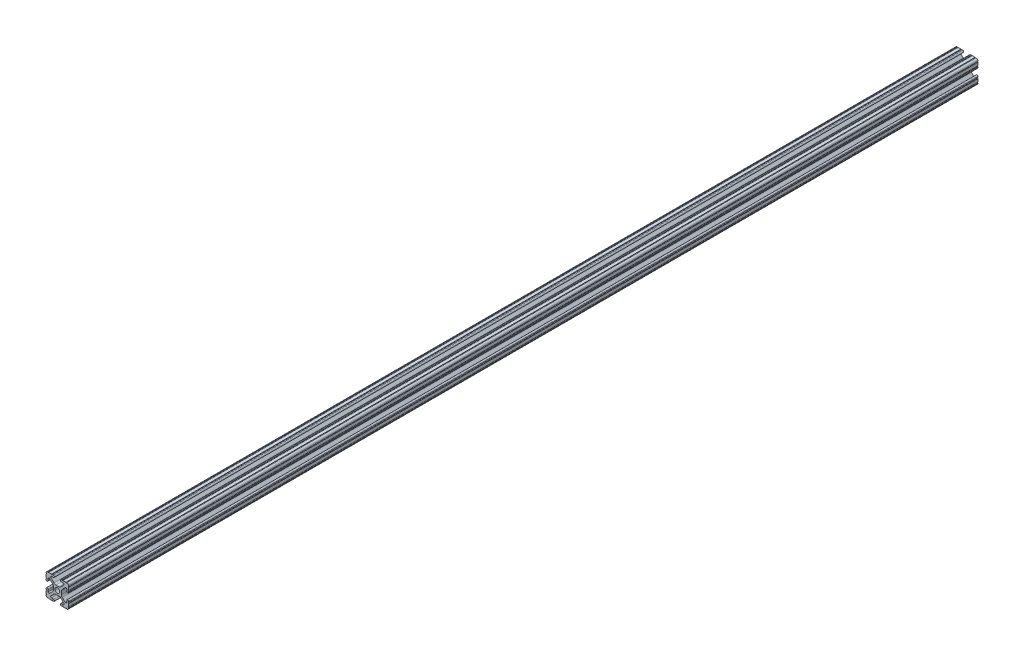
from build123d import *

# Parameters (mm, degrees)
SKETCH1_R           = 2.6035
BOSS_EXTRUDE1_DEPTH = 1016


with BuildPart() as part:
    # Sketch1 → Boss-Extrude1 (new body)
    with BuildSketch(Plane(origin=(0, 0, -450.85), x_dir=(-1, 0, 0), z_dir=(0, 0, -1))):
        with BuildLine():
            Line((12.7, -9.5504), (12.7, -6.3330836))
            ThreePointArc((12.7, -6.3330836), (12.192, -5.8250836), (12.7, -5.3170836))
            Line((12.7, -5.3170836), (12.7, -4.3434))
            ThreePointArc((12.7, -4.3434), (11.5951, -3.2385), (10.4902, -4.3434))
            Line((10.4902, -4.3434), (10.4902, -6.474794456))
            ThreePointArc((10.4902, -6.474794456), (9.863006367, -7.413456061), (8.75577951, -7.193214945))
            Line((8.75577951, -7.193214945), (5.42573597, -3.863171405))
            ThreePointArc((5.42573597, -3.863171405), (4.737482484, -2.833127272), (4.4958, -1.618107374))
            Line((4.4958, -1.618107374), (4.4958, 1.618107374))
            ThreePointArc((4.4958, 1.618107374), (4.737482484, 2.833127272), (5.42573597, 3.863171405))
            Line((5.42573597, 3.863171405), (8.75577951, 7.193214945))
            ThreePointArc((8.75577951, 7.193214945), (9.863006367, 7.413456061), (10.4902, 6.474794456))
            Line((10.4902, 6.474794456), (10.4902, 4.343399971))
            ThreePointArc((10.4902, 4.343399971), (11.5951, 3.238499971), (12.7, 4.343399971))
            Line((12.7, 4.343399971), (12.7, 5.3170836))
            ThreePointArc((12.7, 5.3170836), (12.192, 5.8250836), (12.7, 6.3330836))
            Line((12.7, 6.3330836), (12.7, 9.5504))
            ThreePointArc((12.7, 9.5504), (12.192000006, 10.058323491), (12.699846982, 10.566399977))
            ThreePointArc((12.699846982, 10.566399977), (12.082522516, 12.082522516), (10.566399977, 12.699846982))
            ThreePointArc((10.566399977, 12.699846982), (10.058323491, 12.192000006), (9.5504, 12.7))
            Line((9.5504, 12.7), (6.3330836, 12.7))
            ThreePointArc((6.3330836, 12.7), (5.8250836, 12.192), (5.3170836, 12.7))
            Line((5.3170836, 12.7), (4.3434, 12.7))
            ThreePointArc((4.3434, 12.7), (3.2385, 11.5951), (4.3434, 10.4902))
            Line((4.3434, 10.4902), (6.474794456, 10.4902))
            ThreePointArc((6.474794456, 10.4902), (7.413456061, 9.863006367), (7.193214945, 8.75577951))
            Line((7.193214945, 8.75577951), (3.863171405, 5.42573597))
            ThreePointArc((3.863171405, 5.42573597), (2.833127272, 4.737482484), (1.618107374, 4.4958))
            Line((1.618107374, 4.4958), (-1.618107374, 4.4958))
            ThreePointArc((-1.618107374, 4.4958), (-2.833127272, 4.737482484), (-3.863171405, 5.42573597))
            Line((-3.863171405, 5.42573597), (-7.193214945, 8.75577951))
            ThreePointArc((-7.193214945, 8.75577951), (-7.413456061, 9.863006367), (-6.474794456, 10.4902))
            Line((-6.474794456, 10.4902), (-4.343399971, 10.4902))
            ThreePointArc((-4.343399971, 10.4902), (-3.238499971, 11.5951), (-4.343399971, 12.7))
            Line((-4.343399971, 12.7), (-5.3170836, 12.7))
            ThreePointArc((-5.3170836, 12.7), (-5.8250836, 12.192), (-6.3330836, 12.7))
            Line((-6.3330836, 12.7), (-9.5504, 12.7))
            ThreePointArc((-9.5504, 12.7), (-10.058323491, 12.192000006), (-10.566399977, 12.699846982))
            ThreePointArc((-10.566399977, 12.699846982), (-12.082522516, 12.082522516), (-12.699846982, 10.566399977))
            ThreePointArc((-12.699846982, 10.566399977), (-12.192000006, 10.058323491), (-12.7, 9.5504))
            Line((-12.7, 9.5504), (-12.7, 6.3330836))
            ThreePointArc((-12.7, 6.3330836), (-12.192, 5.8250836), (-12.7, 5.3170836))
            Line((-12.7, 5.3170836), (-12.7, 4.3434))
            ThreePointArc((-12.7, 4.3434), (-11.5951, 3.2385), (-10.4902, 4.3434))
            Line((-10.4902, 4.3434), (-10.4902, 6.474794456))
            ThreePointArc((-10.4902, 6.474794456), (-9.863006367, 7.413456061), (-8.75577951, 7.193214945))
            Line((-8.75577951, 7.193214945), (-5.42573597, 3.863171405))
            ThreePointArc((-5.42573597, 3.863171405), (-4.737482484, 2.833127272), (-4.4958, 1.618107374))
            Line((-4.4958, 1.618107374), (-4.4958, -1.618107374))
            ThreePointArc((-4.4958, -1.618107374), (-4.737482484, -2.833127272), (-5.42573597, -3.863171405))
            Line((-5.42573597, -3.863171405), (-8.75577951, -7.193214945))
            ThreePointArc((-8.75577951, -7.193214945), (-9.863006367, -7.413456061), (-10.4902, -6.474794456))
            Line((-10.4902, -6.474794456), (-10.4902, -4.343399971))
            ThreePointArc((-10.4902, -4.343399971), (-11.5951, -3.238499971), (-12.7, -4.343399971))
            Line((-12.7, -4.343399971), (-12.7, -5.3170836))
            ThreePointArc((-12.7, -5.3170836), (-12.192, -5.8250836), (-12.7, -6.3330836))
            Line((-12.7, -6.3330836), (-12.7, -9.5504))
            ThreePointArc((-12.7, -9.5504), (-12.192000006, -10.058323491), (-12.699846982, -10.566399977))
            ThreePointArc((-12.699846982, -10.566399977), (-12.082522516, -12.082522516), (-10.566399977, -12.699846982))
            ThreePointArc((-10.566399977, -12.699846982), (-10.058323491, -12.192000006), (-9.5504, -12.7))
            Line((-9.5504, -12.7), (-6.3330836, -12.7))
            ThreePointArc((-6.3330836, -12.7), (-5.8250836, -12.192), (-5.3170836, -12.7))
            Line((-5.3170836, -12.7), (-4.3434, -12.7))
            ThreePointArc((-4.3434, -12.7), (-3.2385, -11.5951), (-4.3434, -10.4902))
            Line((-4.3434, -10.4902), (-6.474794456, -10.4902))
            ThreePointArc((-6.474794456, -10.4902), (-7.413456061, -9.863006367), (-7.193214945, -8.75577951))
            Line((-7.193214945, -8.75577951), (-3.863171405, -5.42573597))
            ThreePointArc((-3.863171405, -5.42573597), (-2.833127272, -4.737482484), (-1.618107374, -4.4958))
            Line((-1.618107374, -4.4958), (1.618107374, -4.4958))
            ThreePointArc((1.618107374, -4.4958), (2.833127272, -4.737482484), (3.863171405, -5.42573597))
            Line((3.863171405, -5.42573597), (7.193214945, -8.75577951))
            ThreePointArc((7.193214945, -8.75577951), (7.413456061, -9.863006367), (6.474794456, -10.4902))
            Line((6.474794456, -10.4902), (4.343399971, -10.4902))
            ThreePointArc((4.343399971, -10.4902), (3.238499971, -11.5951), (4.343399971, -12.7))
            Line((4.343399971, -12.7), (5.3170836, -12.7))
            ThreePointArc((5.3170836, -12.7), (5.8250836, -12.192), (6.3330836, -12.7))
            Line((6.3330836, -12.7), (9.5504, -12.7))
            ThreePointArc((9.5504, -12.7), (10.058323491, -12.192000006), (10.566399977, -12.699846982))
            ThreePointArc((10.566399977, -12.699846982), (12.082522516, -12.082522516), (12.699846982, -10.566399977))
            ThreePointArc((12.699846982, -10.566399977), (12.192000006, -10.058323491), (12.7, -9.5504))
        make_face()
        Circle(SKETCH1_R, mode=Mode.SUBTRACT)
    extrude(amount=-BOSS_EXTRUDE1_DEPTH)


solid = part.part
